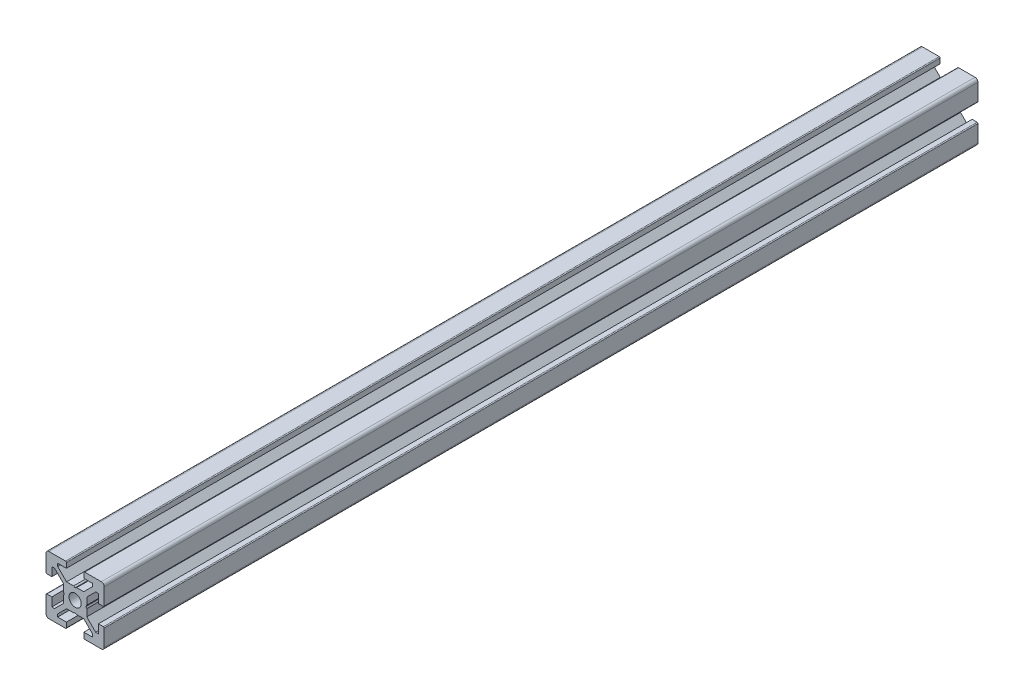
from build123d import *

# Parameters (mm, degrees)
BOSS_EXTRUDE1_DEPTH = 300
SKETCH2_W           = 330
SKETCH2_H           = 2.1
SKETCH4_R           = 2.5
CUT_EXTRUDE1_DEPTH  = 8
SKETCH5_R           = 2.5
CUT_EXTRUDE2_DEPTH  = 8


with BuildPart() as part:
    # Sketch1 → Boss-Extrude1 (new body)
    with BuildSketch(Plane.XY):
        with BuildLine():
            Line((-10, 9), (-10, 3.29999995))
            ThreePointArc((-10, 3.29999995), (-9.912132049, 3.087867916), (-9.7, 3))
            Line((-9.7, 3), (-8, 3))
            Line((-8, 3), (-8, 6))
            Line((-8, 6), (-7.060677, 6))
            Line((-7.060677, 6), (-4, 2.93932965))
            Line((-4, 2.93932965), (-4, 0.519615242))
            Line((-4, 0.519615242), (-3.699996283, -6.437e-06))
            Line((-3.699996283, -6.437e-06), (-4, -0.519628117))
            Line((-4, -0.519628117), (-4, -2.93933725))
            Line((-4, -2.93933725), (-7.0606695, -6))
            Line((-7.0606695, -6), (-8, -6))
            Line((-8, -6), (-8, -3))
            Line((-8, -3), (-9.7, -3))
            ThreePointArc((-9.7, -3), (-9.912132049, -3.087867916), (-10, -3.29999995))
            Line((-10, -3.29999995), (-10, -9))
            ThreePointArc((-10, -9), (-9.707106781, -9.707106781), (-9, -10))
            Line((-9, -10), (-3.29999995, -10))
            ThreePointArc((-3.29999995, -10), (-3.087867916, -9.912132049), (-3, -9.7))
            Line((-3, -9.7), (-3, -8))
            Line((-3, -8), (-6, -8))
            Line((-6, -8), (-6, -7.0606515))
            Line((-6, -7.0606515), (-2.9393489, -4))
            Line((-2.9393489, -4), (-0.519615242, -4))
            Line((-0.519615242, -4), (6.437e-06, -3.699996283))
            Line((6.437e-06, -3.699996283), (0.519628117, -4))
            Line((0.519628117, -4), (2.9393227, -4))
            Line((2.9393227, -4), (6, -7.060677))
            Line((6, -7.060677), (6, -8))
            Line((6, -8), (3, -8))
            Line((3, -8), (3, -9.7))
            ThreePointArc((3, -9.7), (3.087867916, -9.912132049), (3.29999995, -10))
            Line((3.29999995, -10), (9, -10))
            ThreePointArc((9, -10), (9.707106781, -9.707106781), (10, -9))
            Line((10, -9), (10, -3.29999995))
            ThreePointArc((10, -3.29999995), (9.912132049, -3.087867916), (9.7, -3))
            Line((9.7, -3), (8, -3))
            Line((8, -3), (8, -6))
            Line((8, -6), (7.0606435, -6))
            Line((7.0606435, -6), (4, -2.9393482))
            Line((4, -2.9393482), (4, -0.519615242))
            Line((4, -0.519615242), (3.699996283, 6.437e-06))
            Line((3.699996283, 6.437e-06), (4, 0.519628117))
            Line((4, 0.519628117), (4, 2.9393401))
            Line((4, 2.9393401), (7.060651, 6))
            Line((7.060651, 6), (8, 6))
            Line((8, 6), (8, 3))
            Line((8, 3), (9.7, 3))
            ThreePointArc((9.7, 3), (9.912132049, 3.087867916), (10, 3.29999995))
            Line((10, 3.29999995), (10, 9))
            ThreePointArc((10, 9), (9.707106781, 9.707106781), (9, 10))
            Line((9, 10), (3.29999995, 10))
            ThreePointArc((3.29999995, 10), (3.087867916, 9.912132049), (3, 9.7))
            Line((3, 9.7), (3, 8))
            Line((3, 8), (6, 8))
            Line((6, 8), (6, 7.060669))
            Line((6, 7.060669), (2.9393308, 4))
            Line((2.9393308, 4), (0.519615242, 4))
            Line((0.519615242, 4), (-6.437e-06, 3.699996283))
            Line((-6.437e-06, 3.699996283), (-0.519628117, 4))
            Line((-0.519628117, 4), (-2.93935655, 4))
            Line((-2.93935655, 4), (-6, 7.0606435))
            Line((-6, 7.0606435), (-6, 8))
            Line((-6, 8), (-3, 8))
            Line((-3, 8), (-3, 9.7))
            ThreePointArc((-3, 9.7), (-3.087867966, 9.912132034), (-3.3, 10))
            Line((-3.3, 10), (-9, 10))
            ThreePointArc((-9, 10), (-9.707106781, 9.707106781), (-10, 9))
        make_face()
    extrude(amount=-BOSS_EXTRUDE1_DEPTH)

    # Sketch2 → Cut-Revolve1 (revolve, cut)
    with BuildSketch(Plane(origin=(0, 0, 0), x_dir=(0, 0, -1), z_dir=(1, 0, 0))):
        with Locations((165, 1.05)):
            Rectangle(SKETCH2_W, SKETCH2_H)
    revolve(axis=Axis((0, 0, -330), (0, 0, 1)), mode=Mode.SUBTRACT)

    # Sketch4 → Cut-Extrude1 (cut)
    with BuildSketch(Plane(origin=(4, 0, 0), x_dir=(0, 0, -1), z_dir=(1, 0, 0))):
        with Locations((10, 6.437e-06)):
            Circle(SKETCH4_R)
        with Locations((290, 6.437e-06)):
            Circle(SKETCH4_R)
    extrude(amount=-CUT_EXTRUDE1_DEPTH, mode=Mode.SUBTRACT)

    # Sketch5 → Cut-Extrude2 (cut)
    with BuildSketch(Plane(origin=(0, 4, 0), x_dir=(1, 0, 0), z_dir=(0, 1, 0))):
        with Locations((-6.437e-06, 290)):
            Circle(SKETCH5_R)
        with Locations((-6.437e-06, 10)):
            Circle(SKETCH5_R)
    extrude(amount=-CUT_EXTRUDE2_DEPTH, mode=Mode.SUBTRACT)


solid = part.part
